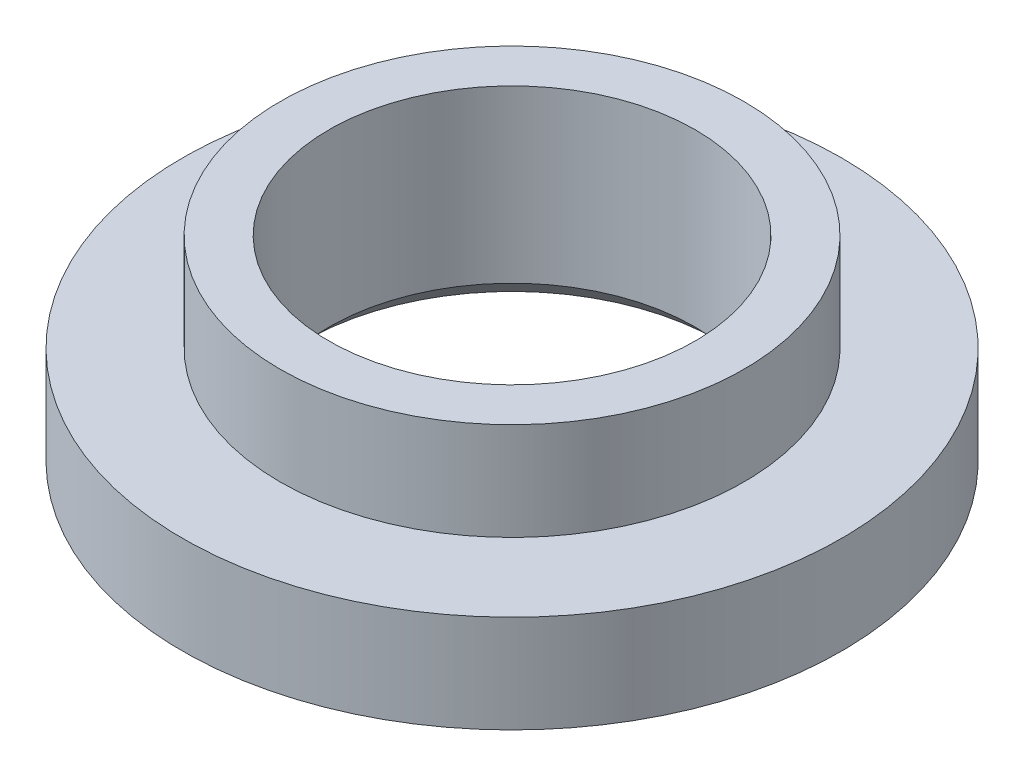
from build123d import *

# Parameters (mm, degrees)
CHAMFER1_SIZE = 0.2


with BuildPart() as part:
    # Sketch1 → Revolve1 (revolve)
    with BuildSketch(Plane.XY):
        Polygon((1.5, 0), (2.7, 0), (2.7, 0.8), (1.9, 0.8), (1.9, 1.6), (1.5, 1.6), align=None)
    revolve(axis=Axis((0, 0, 0), (0, 1, 0)))

    # Chamfer1
    chamfer1_edges = [part.edges().sort_by_distance(p)[0] for p in [
        (-1.5, 0, 0),
    ]]
    chamfer(chamfer1_edges, length=CHAMFER1_SIZE)


solid = part.part
